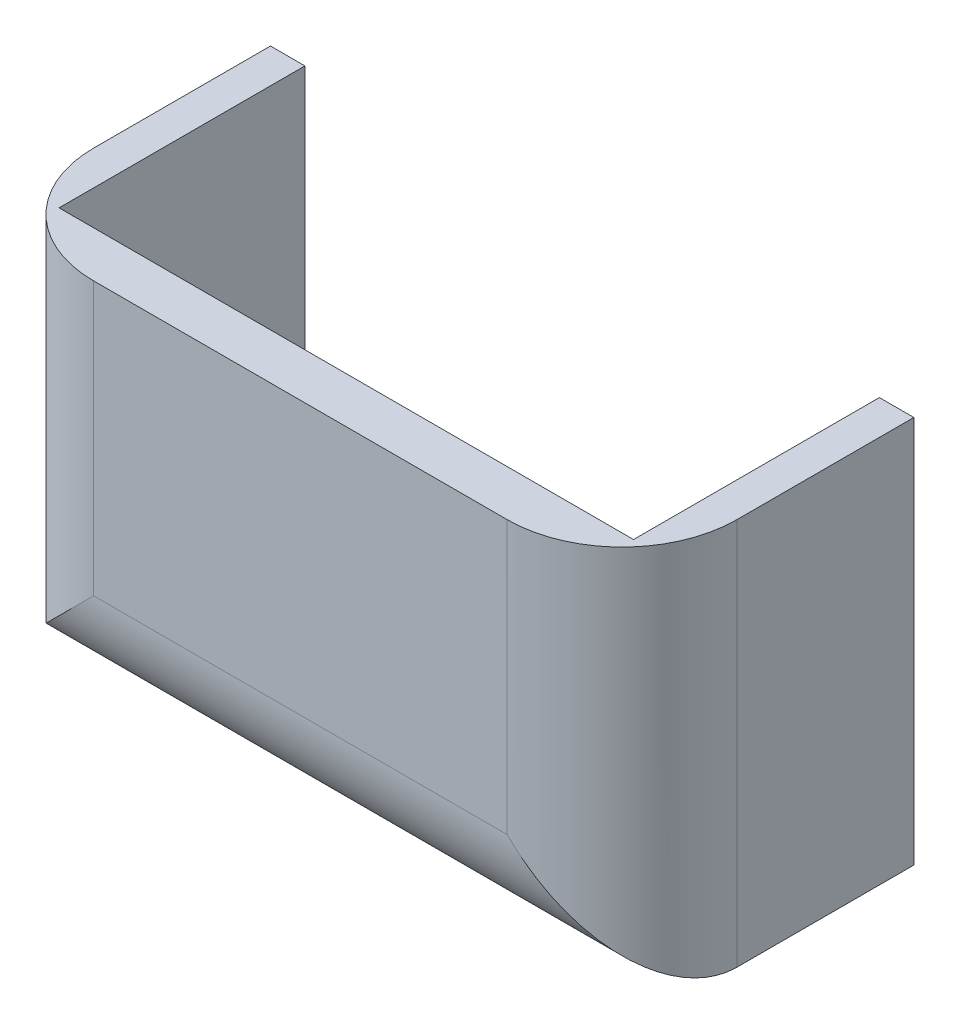
from build123d import *

# Parameters (mm, degrees)
SKETCH1_W           = 56
SKETCH1_H           = 36.73970361
SKETCH1_W_2         = 50
SKETCH1_H_2         = 30.73970361
BOSS_EXTRUDE1_DEPTH = 25.4
SKETCH2_W           = 56
SKETCH2_H           = 36.73970361
BOSS_EXTRUDE2_DEPTH = 4
FILLET1_R           = 10
SKETCH3_W           = 56
SKETCH3_H           = 3
CUT_EXTRUDE1_DEPTH  = 28


with BuildPart() as part:
    # Sketch1 → Boss-Extrude1 (new body)
    with BuildSketch(Plane.XY):
        with Locations((0, -51.412888934)):
            Rectangle(SKETCH1_W, SKETCH1_H)
        with Locations((0, -51.412888934)):
            Rectangle(SKETCH1_W_2, SKETCH1_H_2, mode=Mode.SUBTRACT)
    extrude(amount=BOSS_EXTRUDE1_DEPTH)

    # Sketch2 → Boss-Extrude2 (add)
    with BuildSketch(Plane.XY.offset(25.4)):
        with Locations((0, -51.412888934)):
            Rectangle(SKETCH2_W, SKETCH2_H)
    extrude(amount=-BOSS_EXTRUDE2_DEPTH)

    # Fillet1
    fillet1_edges = [part.edges().sort_by_distance(p)[0] for p in [
        (28, -51.412888934, 25.4),
        (-28, -51.412888934, 25.4),
        (0, -69.782740739, 25.4),
    ]]
    fillet(fillet1_edges, radius=FILLET1_R)

    # Sketch3 → Cut-Extrude1 (cut)
    with BuildSketch(Plane(origin=(0, 0, 0), x_dir=(-1, 0, 0), z_dir=(0, 0, -1))):
        with Locations((0, -34.543037129)):
            Rectangle(SKETCH3_W, SKETCH3_H)
    extrude(amount=-CUT_EXTRUDE1_DEPTH, mode=Mode.SUBTRACT)


solid = part.part
